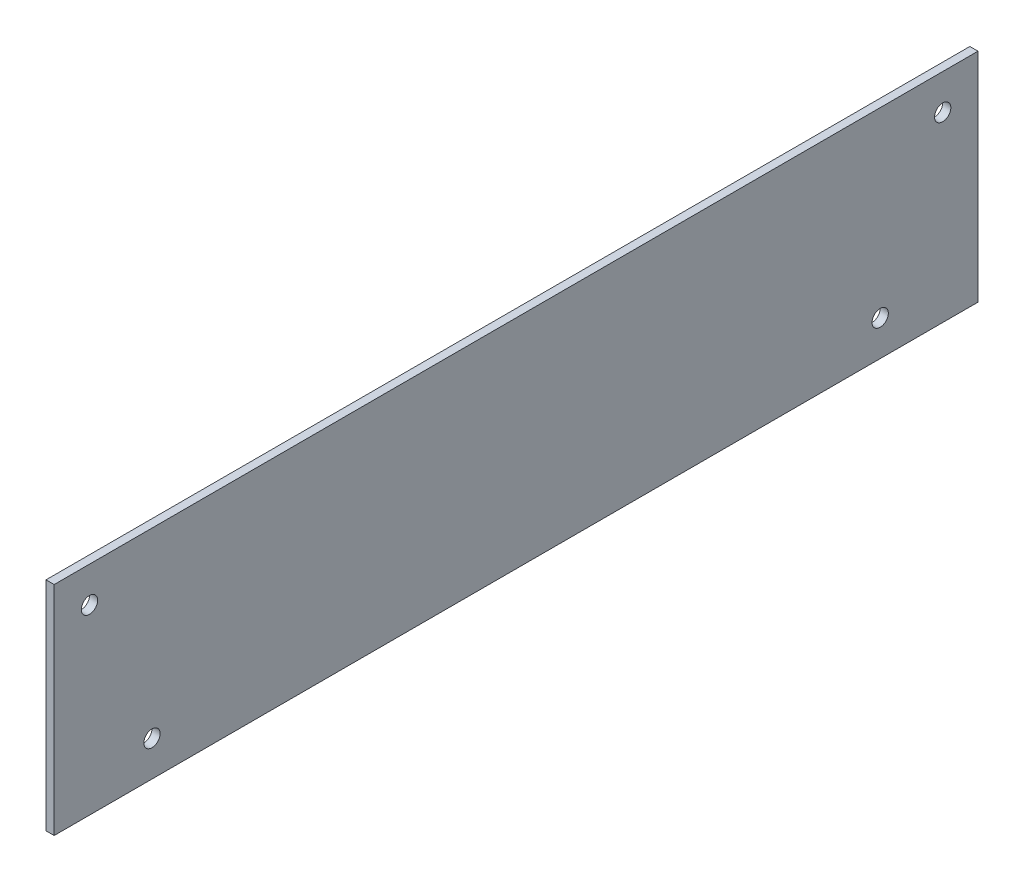
from build123d import *

# Parameters (mm, degrees)
SKETCH1_W               = 170
SKETCH1_H               = 40
BOSS_EXTRUDE1_DEPTH     = 1.5
CUT_EXTRUDE1_DEPTH      = 15
CUT_EXTRUDE1_DEPTH_BACK = 15
SKETCH2_R               = 1.5


with BuildPart() as part:
    # Sketch1 → Boss-Extrude1 (new body)
    with BuildSketch(Plane(origin=(0, 0, 0), x_dir=(0, 0, -1), z_dir=(1, 0, 0))):
        with Locations((85, 20)):
            Rectangle(SKETCH1_W, SKETCH1_H)
    extrude(amount=BOSS_EXTRUDE1_DEPTH)

    # Sketch2 → Cut-Extrude1 (cut, two sides: drawn at the far end of the back side and taken through both)
    with BuildSketch(Plane(origin=(1.5, 0, 0), x_dir=(0, 0, -1), z_dir=(1, 0, 0)).offset(-CUT_EXTRUDE1_DEPTH_BACK)):
        with Locations((18, 6.5)):
            Circle(SKETCH2_R)
        with Locations((152, 6.5)):
            Circle(SKETCH2_R)
        with Locations((163.5, 33.5)):
            Circle(SKETCH2_R)
        with Locations((6.5, 33.5)):
            Circle(SKETCH2_R)
    extrude(amount=CUT_EXTRUDE1_DEPTH + CUT_EXTRUDE1_DEPTH_BACK, mode=Mode.SUBTRACT)


solid = part.part
